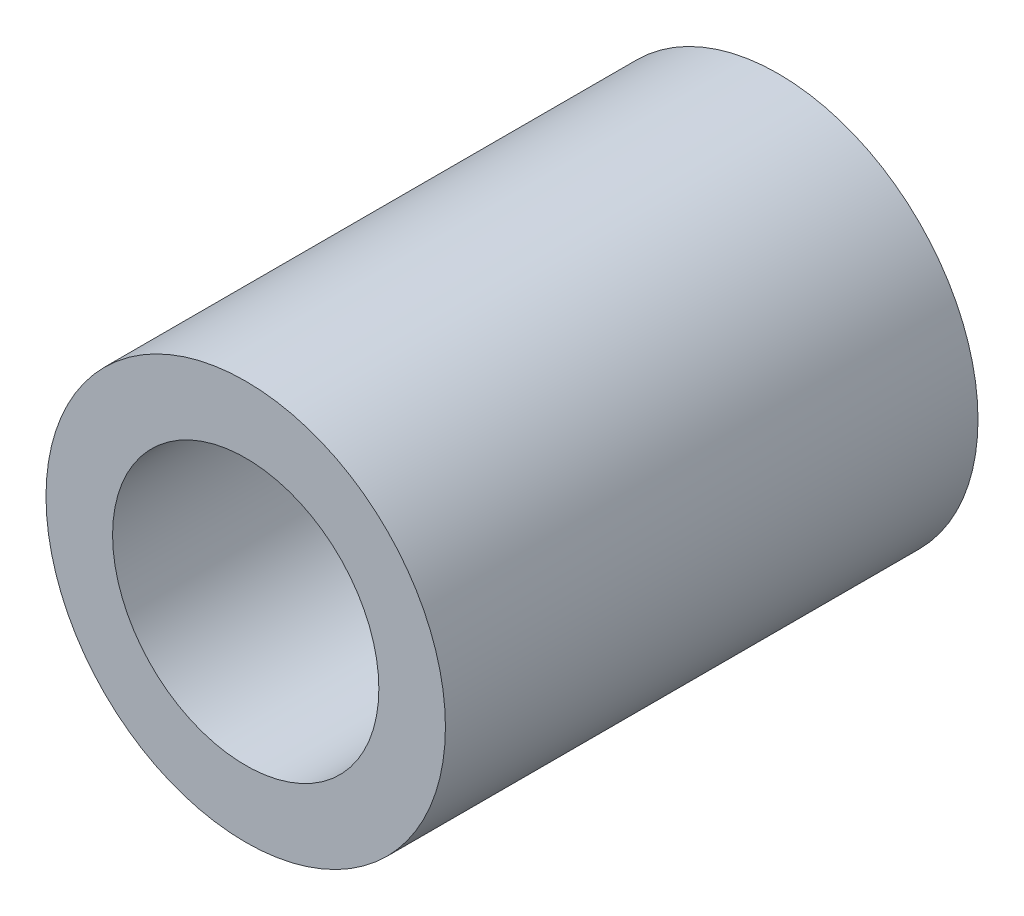
from build123d import *

# Parameters (mm, degrees)
SKETCH1_R           = 4.7625
SKETCH1_R_2         = 3.175
BOSS_EXTRUDE1_DEPTH = 12.7


with BuildPart() as part:
    # Sketch1 → Boss-Extrude1 (new body)
    with BuildSketch(Plane.XY):
        Circle(SKETCH1_R)
        Circle(SKETCH1_R_2, mode=Mode.SUBTRACT)
    extrude(amount=BOSS_EXTRUDE1_DEPTH)


solid = part.part
